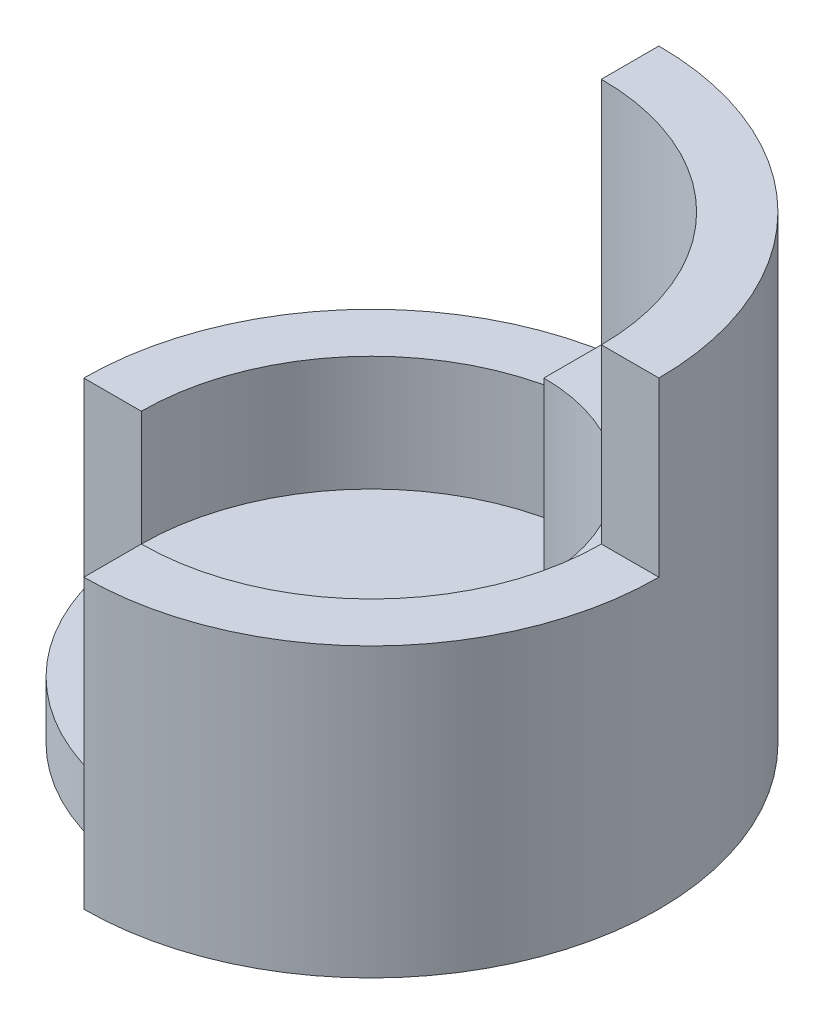
from build123d import *

# Parameters (mm, degrees)
SKETCH1_R               = 1
BOSS_EXTRUDE1_DEPTH     = 1
BOSS_EXTRUDE2_DEPTH     = 4
BOSS_EXTRUDE3_DEPTH     = 3
SKETCH6_W               = 5
SKETCH6_H               = 3
CUT_EXTRUDE1_DEPTH      = 6
CUT_EXTRUDE2_DEPTH      = 3
CUT_EXTRUDE2_DEPTH_BACK = 1
SKETCH7_R               = 4
BOSS_EXTRUDE4_DEPTH     = 2


with BuildPart() as part:
    # Sketch1 → Boss-Extrude1 (new body)
    with BuildSketch(Plane(origin=(0, 0, 0), x_dir=(1, 0, 0), z_dir=(0, 1, 0))):
        with BuildLine():
            ThreePointArc((0, -5), (3.535533906, 3.535533906), (-5, 0))
            Line((-5, 0), (-4, 0))
            ThreePointArc((-4, 0), (-2.828427125, -2.828427125), (0, -4))
            Line((0, -4), (0, -5))
        make_face()
        Circle(SKETCH1_R, mode=Mode.SUBTRACT)
    extrude(amount=BOSS_EXTRUDE1_DEPTH)

    # Sketch2 → Boss-Extrude2 (add)
    with BuildSketch(Plane(origin=(0, 1, 0), x_dir=(1, 0, 0), z_dir=(0, 1, 0))):
        with BuildLine():
            Line((0, 3), (0, 5))
            ThreePointArc((0, 5), (5, 0), (0, -5))
            Line((0, -5), (0, -3))
            ThreePointArc((0, -3), (3, 0), (0, 3))
        make_face()
    extrude(amount=BOSS_EXTRUDE2_DEPTH)

    # Sketch4 → Boss-Extrude3 (add)
    with BuildSketch(Plane(origin=(0, 5, 0), x_dir=(1, 0, 0), z_dir=(0, 1, 0))):
        with BuildLine():
            Line((0, 5), (0, 4))
            ThreePointArc((0, 4), (3.883896034, 0), (0, -4))
            Line((0, -4), (0, -5))
            ThreePointArc((0, -5), (5, 0), (0, 5))
        make_face()
    extrude(amount=BOSS_EXTRUDE3_DEPTH)

    # Sketch6 → Cut-Extrude1 (cut)
    with BuildSketch(Plane.ZY):
        with Locations((2.5, 6.5)):
            Rectangle(SKETCH6_W, SKETCH6_H)
    extrude(amount=-CUT_EXTRUDE1_DEPTH, mode=Mode.SUBTRACT)

    # Sketch7 → Cut-Extrude2 (cut, two sides: drawn at the far end of the back side and taken through both)
    with BuildSketch(Plane(origin=(0, 5, 0), x_dir=(1, 0, 0), z_dir=(0, 1, 0)).offset(-CUT_EXTRUDE2_DEPTH_BACK)):
        Circle(SKETCH7_R)
    extrude(amount=CUT_EXTRUDE2_DEPTH + CUT_EXTRUDE2_DEPTH_BACK, mode=Mode.SUBTRACT)

    # Sketch8 → Boss-Extrude4 (add)
    with BuildSketch(Plane(origin=(0, 1, 0), x_dir=(1, 0, 0), z_dir=(0, 1, 0))):
        with BuildLine():
            Line((0, 5), (0, 4))
            ThreePointArc((0, 4), (-2.828427125, 2.828427125), (-4, 0))
            Line((-4, 0), (-5, 0))
            ThreePointArc((-5, 0), (-3.535533906, 3.535533906), (0, 5))
        make_face()
    extrude(amount=BOSS_EXTRUDE4_DEPTH)


solid = part.part
